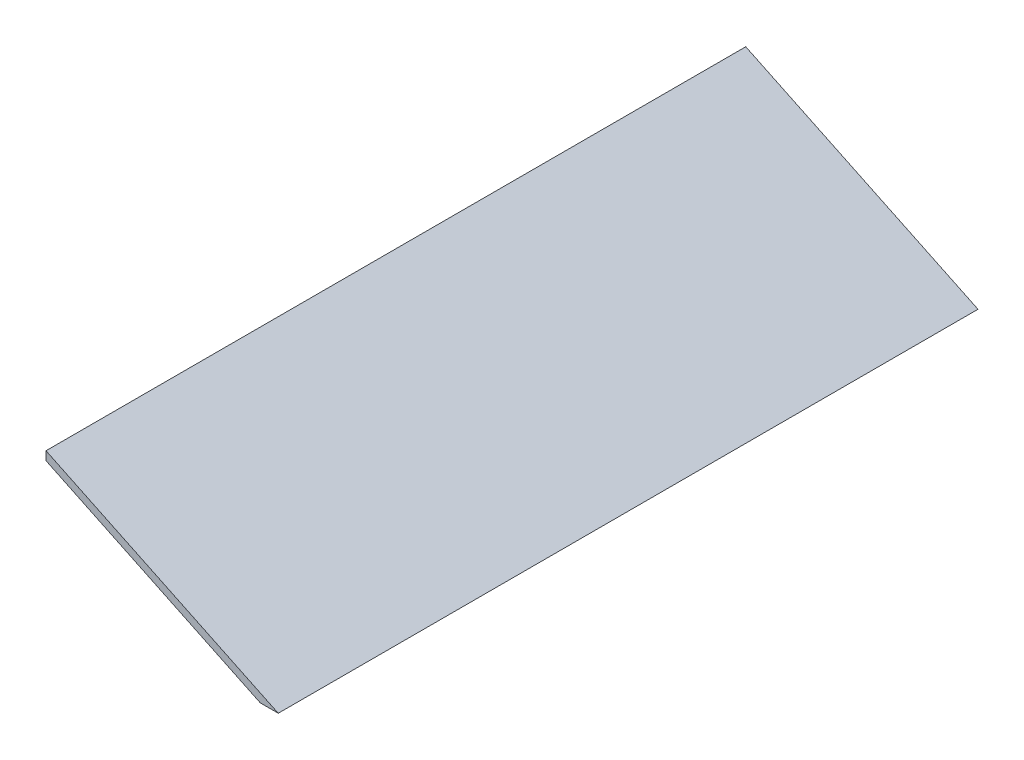
from build123d import *

# Parameters (mm, degrees)
AUFSATZ_LINEAR_AUSTRAGEN1_DEPTH = 450


with BuildPart() as part:
    # Skizze1 → Aufsatz-Linear austragen1 (new body)
    with BuildSketch(Plane.XY):
        Polygon((-331.860776555, 76.524878913), (-331.860776555, 70.981144659), (-194.076621532, 5), (-182.5, 5), align=None)
    extrude(amount=AUFSATZ_LINEAR_AUSTRAGEN1_DEPTH)


solid = part.part
